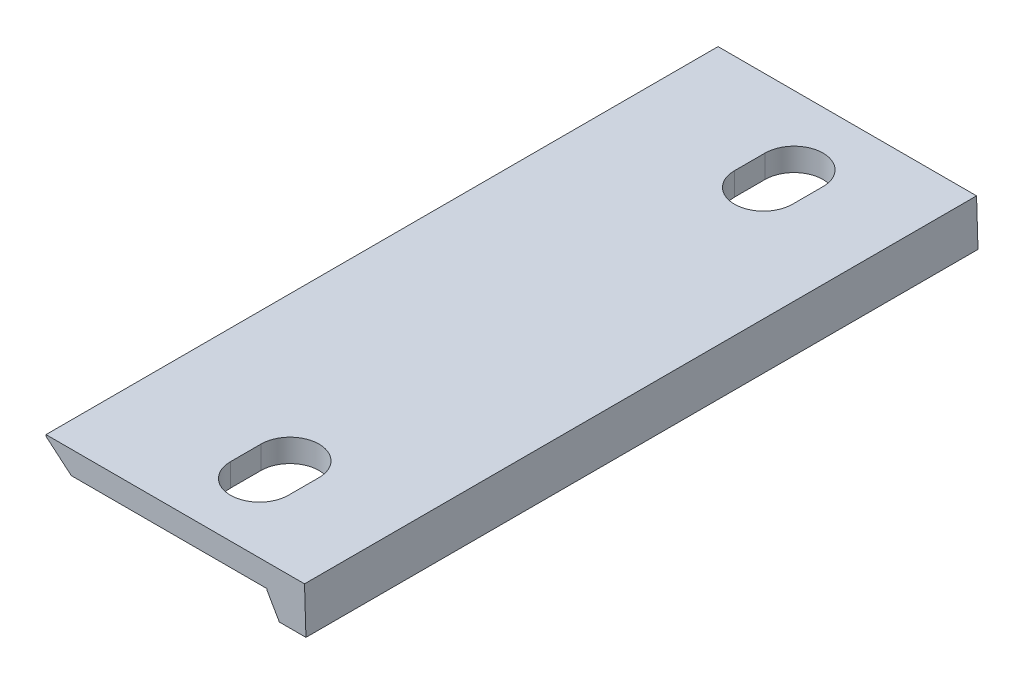
from build123d import *

# Parameters (mm, degrees)
EXTRUDE_1_DEPTH     = 440
CUT_EXTRUDE_1_DEPTH = 30.906162578


with BuildPart() as part:
    # Эскиз1 → Бобышка-Вытянуть1 (new body)
    with BuildSketch(Plane.XY):
        Polygon((169.252902227, 0), (0, 0), (0, -1), (16.565023393, -15), (144.748239349, -15), (144.748239349, -16), (152.776966057, -29.906162578), (170.193520621, -29.906162578), align=None)
    extrude(amount=-EXTRUDE_1_DEPTH)

    # Эскиз4 → Вырез-Вытянуть1 (cut, through all)
    with BuildSketch(Plane(origin=(0, 0, 0), x_dir=(1, 0, 0), z_dir=(0, 1, 0))):
        with BuildLine():
            Line((75.748239349, 65), (75.748239349, 45))
            ThreePointArc((75.748239349, 45), (94.748239349, 26), (113.748239349, 45))
            Line((113.748239349, 45), (113.748239349, 65))
            ThreePointArc((113.748239349, 65), (94.748239349, 84), (75.748239349, 65))
        make_face()
        with BuildLine():
            Line((75.748239349, 395), (75.748239349, 375))
            ThreePointArc((75.748239349, 375), (94.748239349, 356), (113.748239349, 375))
            Line((113.748239349, 375), (113.748239349, 395))
            ThreePointArc((113.748239349, 395), (94.748239349, 414), (75.748239349, 395))
        make_face()
    extrude(amount=-CUT_EXTRUDE_1_DEPTH, mode=Mode.SUBTRACT)


solid = part.part
